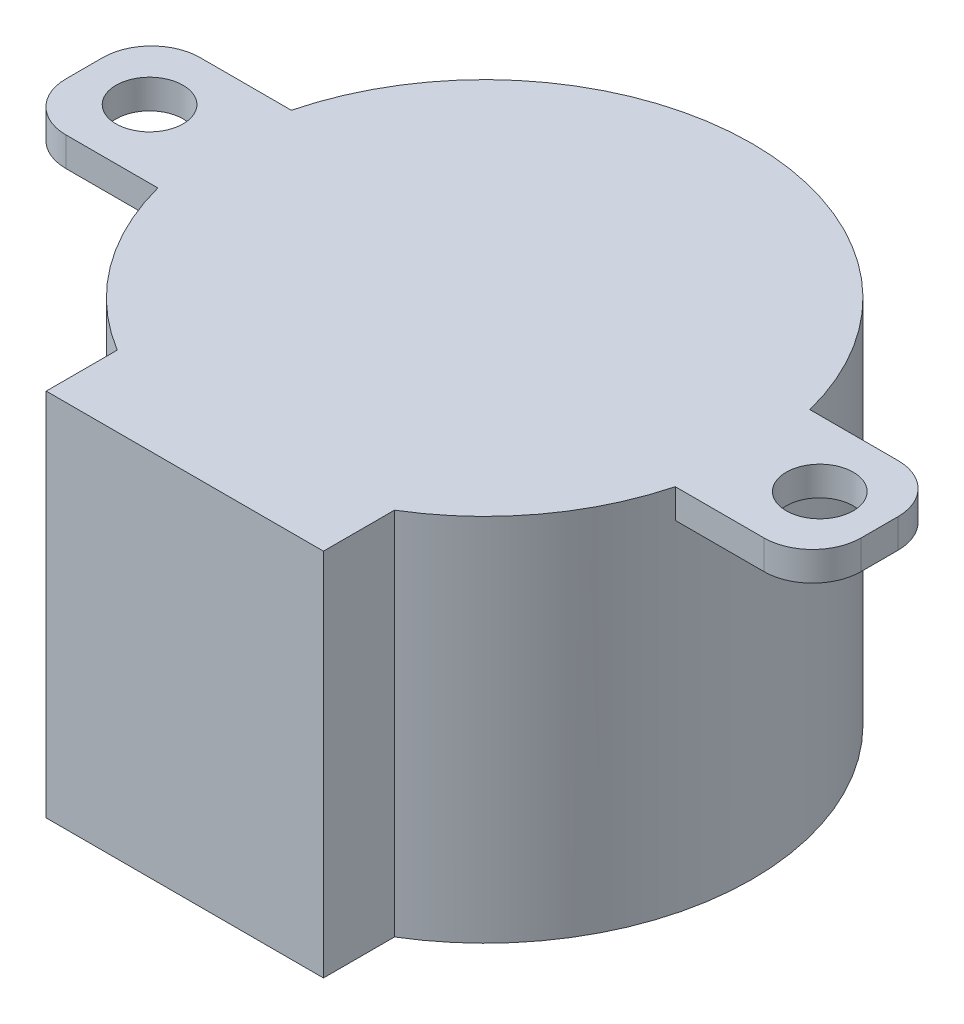
from build123d import *

# Parameters (mm, degrees)
SKETCH1_R           = 1.75
BOSS_EXTRUDE1_DEPTH = 19.304
CUT_EXTRUDE1_START  = -19.304
CUT_EXTRUDE1_DEPTH  = 17.78


with BuildPart() as part:
    # Sketch1 → Boss-Extrude1 (new body)
    with BuildSketch(Plane(origin=(0, 0, 0), x_dir=(1, 0, 0), z_dir=(0, 1, 0))):
        with BuildLine():
            Line((-7.239, -11.948128682), (-7.239, -15.65830815))
            Line((-7.239, -15.65830815), (7.239, -15.65830815))
            Line((7.239, -15.65830815), (7.239, -11.948128682))
            ThreePointArc((7.239, -11.948128682), (11.19086866, -8.362138401), (13.509839525, -3.556))
            Line((13.509839525, -3.556), (18.139005902, -3.556))
            ThreePointArc((18.139005902, -3.556), (19.935057126, -2.812051224), (20.679005902, -1.016))
            Line((20.679005902, -1.016), (20.679005902, 0.904))
            ThreePointArc((20.679005902, 0.904), (19.935057126, 2.700051224), (18.139005902, 3.444))
            Line((18.139005902, 3.444), (13.538824321, 3.444))
            ThreePointArc((13.538824321, 3.444), (0, 13.97), (-13.538824321, 3.444))
            Line((-13.538824321, 3.444), (-18.305445148, 3.444))
            ThreePointArc((-18.305445148, 3.444), (-20.101496373, 2.700051224), (-20.845445148, 0.904))
            Line((-20.845445148, 0.904), (-20.845445148, -1.016))
            ThreePointArc((-20.845445148, -1.016), (-20.101496373, -2.812051224), (-18.305445148, -3.556))
            Line((-18.305445148, -3.556), (-13.509839525, -3.556))
            ThreePointArc((-13.509839525, -3.556), (-11.19086866, -8.362138401), (-7.239, -11.948128682))
        make_face()
        with Locations((17.499965, 0)):
            Circle(SKETCH1_R, mode=Mode.SUBTRACT)
        with Locations((-17.499965, 0)):
            Circle(SKETCH1_R, mode=Mode.SUBTRACT)
    extrude(amount=BOSS_EXTRUDE1_DEPTH)

    # Sketch2 → Cut-Extrude1 (cut)
    with BuildSketch(Plane(origin=(0, 19.304, 0), x_dir=(1, 0, 0), z_dir=(0, 1, 0)).offset(CUT_EXTRUDE1_START)):
        with BuildLine():
            Line((-13.538824321, 3.444), (-18.305445148, 3.444))
            Line((-18.305445148, 3.444), (-22.379136798, 3.444))
            Line((-22.379136798, 3.444), (-22.379136798, -3.598718101))
            Line((-22.379136798, -3.598718101), (-18.305445148, -3.556))
            Line((-18.305445148, -3.556), (-13.509839525, -3.556))
            ThreePointArc((-13.509839525, -3.556), (-13.969880242, -0.057844875), (-13.538824321, 3.444))
        make_face()
        with BuildLine():
            Line((18.305445148, -3.556), (13.509839525, -3.556))
            ThreePointArc((13.509839525, -3.556), (13.969880242, -0.057844875), (13.538824321, 3.444))
            Line((13.538824321, 3.444), (18.305445148, 3.444))
            ThreePointArc((18.305445148, 3.444), (20.101496373, 2.700051224), (20.845445148, 0.904))
            Line((20.845445148, 0.904), (20.777862254, -1.598025477))
            ThreePointArc((20.777862254, -1.598025477), (19.998954522, -3.154465794), (18.305445148, -3.556))
        make_face()
    extrude(amount=CUT_EXTRUDE1_DEPTH, mode=Mode.SUBTRACT)


solid = part.part
